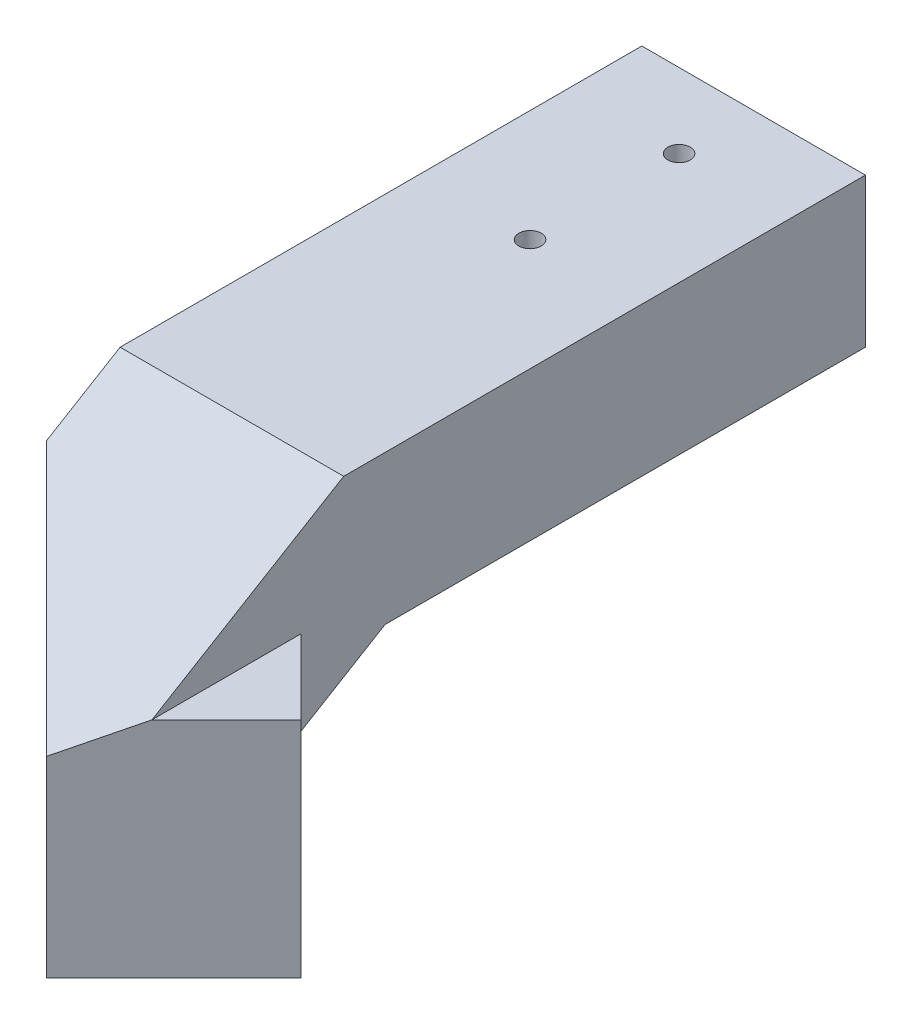
from build123d import *

# Parameters (mm, degrees)
SALIENTE_EXTRUIR2_DEPTH = 30
CROQUIS3_W              = 60.629420227
CROQUIS3_H              = 60.965705304
CORTAR_EXTRUIR1_DEPTH   = 30
CROQUIS4_R              = 3
CORTAR_EXTRUIR2_DEPTH   = 54.545510937
CROQUIS5_W              = 28.284271248
CROQUIS5_H              = 30
SALIENTE_EXTRUIR3_DEPTH = 14.142136
SALIENTE_EXTRUIR4_DEPTH = 10
CROQUIS7_W              = 23.581736244
CROQUIS7_H              = 30.206171788
CORTAR_EXTRUIR3_DEPTH   = 60
CROQUIS8_R              = 3
CORTAR_EXTRUIR4_DEPTH   = 71.616578937
CROQUIS10_W             = 79.072347139
CROQUIS10_H             = 56.401254602
CORTAR_EXTRUIR5_DEPTH   = 50
CROQUIS12_W             = 30
CROQUIS12_H             = 20
SALIENTE_EXTRUIR6_DEPTH = 20
CROQUIS13_R             = 1.5
CORTAR_EXTRUIR6_DEPTH   = 20


with BuildPart() as part:
    # Croquis2 → Saliente-Extruir2 (new body)
    with BuildSketch(Plane(origin=(0, 0, 0), x_dir=(0, 0, -1), z_dir=(1, 0, 0))):
        Polygon((0, 0), (-50, 0), (-75.724787771, -15.434872663), (-75.724787771, -45.434872663), (-55.724787771, -45.434872663), (-55.724787771, -26.758680242), (-44.460320701, -20), (0, -20), align=None)
    extrude(amount=SALIENTE_EXTRUIR2_DEPTH)

    # Croquis3 → Cortar-Extruir1 (cut)
    with BuildSketch(Plane(origin=(-22.862393886, 0, 22.862393886), x_dir=(0.707106781, 0, 0.707106781), z_dir=(-0.707106781, 0, 0.707106781))):
        with Locations((51.516510193, -19.86952732)):
            Rectangle(CROQUIS3_W, CROQUIS3_H)
    extrude(amount=CORTAR_EXTRUIR1_DEPTH, mode=Mode.SUBTRACT)

    # Croquis4 → Cortar-Extruir2 (cut, through all)
    with BuildSketch(Plane(origin=(-22.862393886, 0, 22.862393886), x_dir=(0.707106781, 0, 0.707106781), z_dir=(-0.707106781, 0, 0.707106781))):
        with Locations((60.616578749, -34.226076292)):
            Circle(CROQUIS4_R)
    extrude(amount=-CORTAR_EXTRUIR2_DEPTH, mode=Mode.SUBTRACT)

    # Croquis5 → Saliente-Extruir3 (add)
    with BuildSketch(Plane(origin=(-22.862393886, 0, 22.862393886), x_dir=(0.707106781, 0, 0.707106781), z_dir=(-0.707106781, 0, 0.707106781))):
        with Locations((60.616578749, -30.434872663)):
            Rectangle(CROQUIS5_W, CROQUIS5_H)
    extrude(amount=-SALIENTE_EXTRUIR3_DEPTH)

    # Croquis6 → Saliente-Extruir4 (add)
    with BuildSketch(Plane(origin=(-22.862393886, 0, 22.862393886), x_dir=(0.707106781, 0, 0.707106781), z_dir=(-0.707106781, 0, 0.707106781))):
        Polygon((32.332307501, -20.758680242), (46.474443125, -26.758680242), (46.474443125, -45.434872663), (74.758714373, -45.434872663), (74.758714373, -15.434872663), (38.378370617, 0), (32.332307501, 0), align=None)
    extrude(amount=SALIENTE_EXTRUIR4_DEPTH)

    # Croquis7 → Cortar-Extruir3 (cut)
    with BuildSketch(Plane(origin=(0, 0, 0), x_dir=(1, 0, 0), z_dir=(0, 1, 0))):
        with Locations((-11.790868122, -58.05803285)):
            Rectangle(CROQUIS7_W, CROQUIS7_H)
    extrude(amount=-CORTAR_EXTRUIR3_DEPTH, mode=Mode.SUBTRACT)

    # Croquis8 → Cortar-Extruir4 (cut, through all)
    with BuildSketch(Plane(origin=(-29.933461698, 0, 29.933461698), x_dir=(0.707106781, 0, 0.707106781), z_dir=(-0.707106781, 0, 0.707106781))):
        with Locations((60.616578749, -35.434872663)):
            Circle(CROQUIS8_R)
    extrude(amount=-CORTAR_EXTRUIR4_DEPTH, mode=Mode.SUBTRACT)

    # Croquis10 → Cortar-Extruir5 (cut)
    with BuildSketch(Plane(origin=(0, 22.058823529, 13.235294118), x_dir=(1, 0, 0), z_dir=(0, 0.857492926, 0.514495755))):
        with Locations((7.523719949, -68.590647859)):
            Rectangle(CROQUIS10_W, CROQUIS10_H)
    extrude(amount=CORTAR_EXTRUIR5_DEPTH, mode=Mode.SUBTRACT)

    # Croquis12 → Saliente-Extruir6 (add)
    with BuildSketch(Plane(origin=(0, 0, 0), x_dir=(-1, 0, 0), z_dir=(0, 0, -1))):
        with Locations((-15, -10)):
            Rectangle(CROQUIS12_W, CROQUIS12_H)
    extrude(amount=SALIENTE_EXTRUIR6_DEPTH)

    # Croquis13 → Cortar-Extruir6 (cut)
    with BuildSketch(Plane.XZ.offset(20)):
        with Locations((15, -10)):
            Circle(CROQUIS13_R)
        with Locations((15, 10)):
            Circle(CROQUIS13_R)
    extrude(amount=-CORTAR_EXTRUIR6_DEPTH, mode=Mode.SUBTRACT)


solid = part.part
